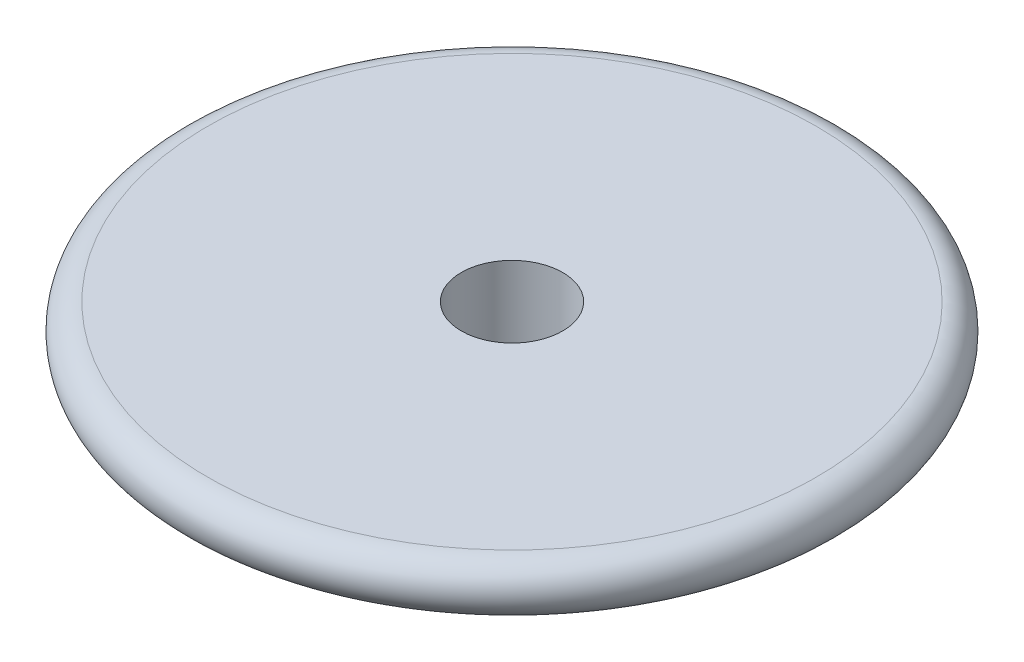
from build123d import *

# Parameters (mm, degrees)
SKETCH2_R          = 2
CUT_EXTRUDE1_DEPTH = 5


with BuildPart() as part:
    # Sketch1 → Revolve1 (revolve)
    with BuildSketch(Plane(origin=(0, 0, 0), x_dir=(0, 0, -1), z_dir=(1, 0, 0))):
        with BuildLine():
            Line((0, 0), (-12, 0))
            ThreePointArc((-12, 0), (-12.986393924, -0.835601013), (-12.324324324, -1.945945946))
            ThreePointArc((-12.324324324, -1.945945946), (-6.247161518, -3.482969106), (0, -4))
            Line((0, -4), (0, 0))
        make_face()
    revolve(axis=Axis((0, -4, 0), (0, 1, 0)))

    # Sketch2 → Cut-Extrude1 (cut, through all)
    with BuildSketch(Plane(origin=(0, 0, 0), x_dir=(1, 0, 0), z_dir=(0, 1, 0))):
        Circle(SKETCH2_R)
    extrude(amount=-CUT_EXTRUDE1_DEPTH, mode=Mode.SUBTRACT)


solid = part.part
